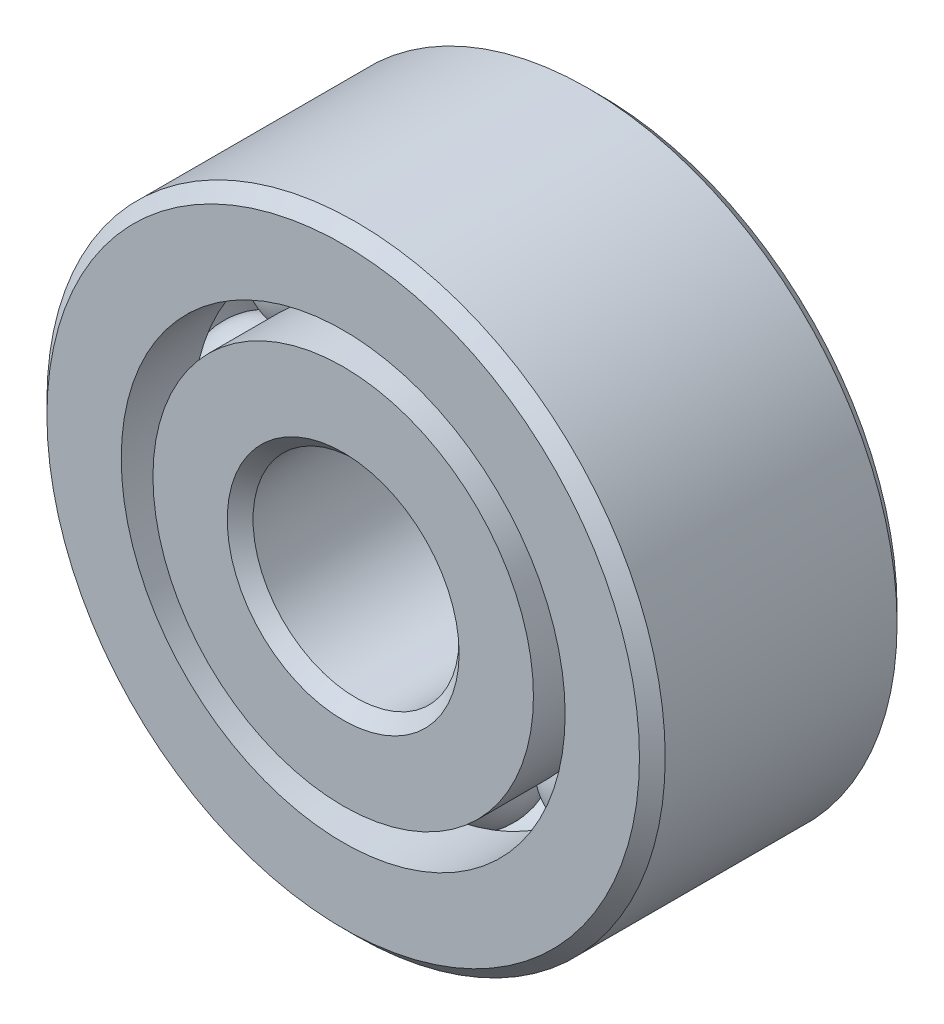
from build123d import *

# Parameters (mm, degrees)
CIRPATTERN1_COUNT = 8


with BuildPart() as part:
    # Sketch1 → Revolve1 (revolve)
    with BuildSketch(Plane(origin=(0, 0, 0), x_dir=(0, 0, -1), z_dir=(1, 0, 0))):
        with BuildLine():
            Line((1.7859375, 4.7625), (-1.7859375, 4.7625))
            Line((-1.7859375, 4.7625), (-1.984375, 4.5640625))
            Line((-1.984375, 4.5640625), (-1.984375, 3.419230769))
            Line((-1.984375, 3.419230769), (-0.881944444, 3.419230769))
            ThreePointArc((-0.881944444, 3.419230769), (0, 4.090136422), (0.881944444, 3.419230769))
            Line((0.881944444, 3.419230769), (1.984375, 3.419230769))
            Line((1.984375, 3.419230769), (1.984375, 4.5640625))
            Line((1.984375, 4.5640625), (1.7859375, 4.7625))
        make_face()
    revolve(axis=Axis((0, 0, 1.984375), (0, 0, -1)))


with BuildPart() as body_2:
    # Sketch3 → Revolve3 (revolve)
    with BuildSketch(Plane(origin=(0, 0, 0), x_dir=(0, 0, -1), z_dir=(1, 0, 0))):
        with BuildLine():
            Line((-1.984375, 2.930769231), (-0.881944444, 2.930769231))
            ThreePointArc((-0.881944444, 2.930769231), (0, 2.259863578), (0.881944444, 2.930769231))
            Line((0.881944444, 2.930769231), (1.984375, 2.930769231))
            Line((1.984375, 2.930769231), (1.984375, 1.7859375))
            Line((1.984375, 1.7859375), (1.7859375, 1.5875))
            Line((1.7859375, 1.5875), (-1.7859375, 1.5875))
            Line((-1.7859375, 1.5875), (-1.984375, 1.7859375))
            Line((-1.984375, 1.7859375), (-1.984375, 2.930769231))
        make_face()
    revolve(axis=Axis((0, 0, 1.984375), (0, 0, -1)))


with BuildPart() as body_3:
    # Sketch4 → Revolve4 (revolve)
    with BuildSketch(Plane(origin=(0, 0, 0), x_dir=(0, 0, -1), z_dir=(1, 0, 0))):
        with BuildLine():
            Line((-0.915136422, 3.175), (0.915136422, 3.175))
            ThreePointArc((0.915136422, 3.175), (0, 4.090136422), (-0.915136422, 3.175))
        make_face()
    revolve(axis=Axis((0, 3.175, 0.915136422), (0, 0, -1)))


with BuildPart() as cirpattern1_1:
    # CirPattern1: pattern copy
    add(body_3.part.rotate(Axis((0, 0, 0), (0, 0, 1)), 1 * 360 / CIRPATTERN1_COUNT))


with BuildPart() as cirpattern1_2:
    # CirPattern1: pattern copy
    add(body_3.part.rotate(Axis((0, 0, 0), (0, 0, 1)), 2 * 360 / CIRPATTERN1_COUNT))


with BuildPart() as cirpattern1_3:
    # CirPattern1: pattern copy
    add(body_3.part.rotate(Axis((0, 0, 0), (0, 0, 1)), 3 * 360 / CIRPATTERN1_COUNT))


with BuildPart() as cirpattern1_4:
    # CirPattern1: pattern copy
    add(body_3.part.rotate(Axis((0, 0, 0), (0, 0, 1)), 4 * 360 / CIRPATTERN1_COUNT))


with BuildPart() as cirpattern1_5:
    # CirPattern1: pattern copy
    add(body_3.part.rotate(Axis((0, 0, 0), (0, 0, 1)), 5 * 360 / CIRPATTERN1_COUNT))


with BuildPart() as cirpattern1_6:
    # CirPattern1: pattern copy
    add(body_3.part.rotate(Axis((0, 0, 0), (0, 0, 1)), 6 * 360 / CIRPATTERN1_COUNT))


with BuildPart() as cirpattern1_7:
    # CirPattern1: pattern copy
    add(body_3.part.rotate(Axis((0, 0, 0), (0, 0, 1)), 7 * 360 / CIRPATTERN1_COUNT))


solid = Compound([part.part, body_2.part, body_3.part, cirpattern1_1.part, cirpattern1_2.part, cirpattern1_3.part, cirpattern1_4.part, cirpattern1_5.part, cirpattern1_6.part, cirpattern1_7.part])
